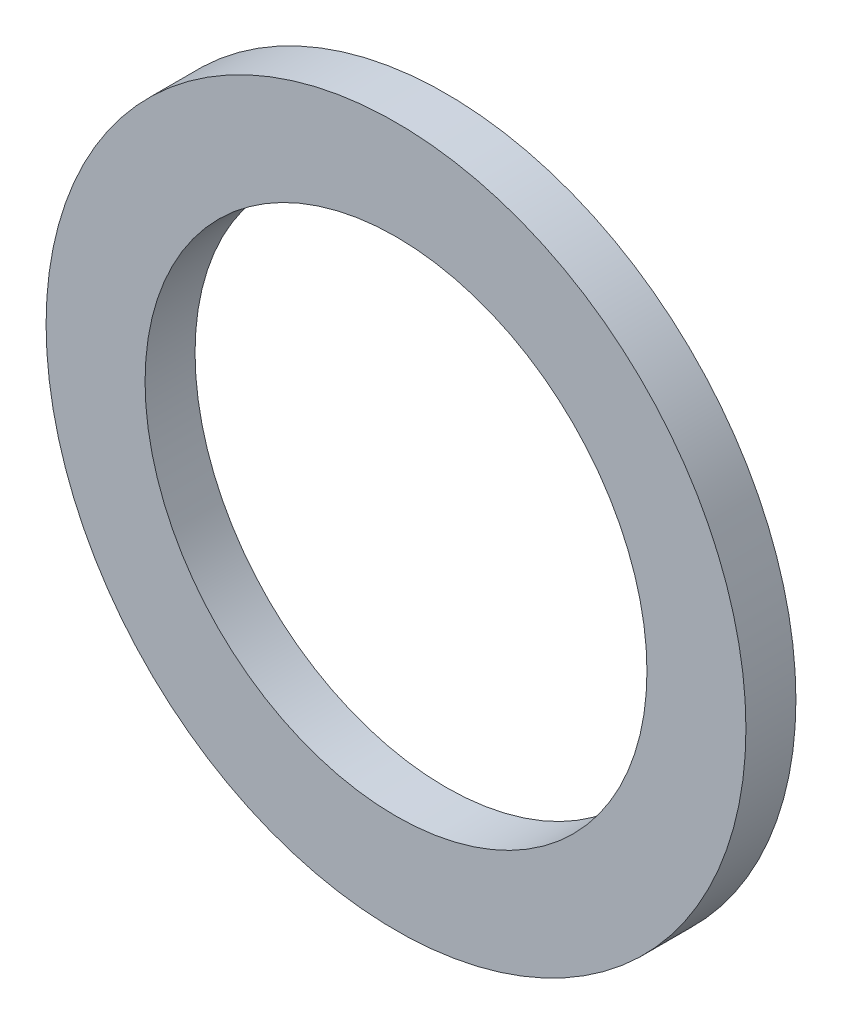
from build123d import *

# Parameters (mm, degrees)
SKETCH1_R           = 22.225
SKETCH1_R_2         = 15.9385
BOSS_EXTRUDE1_DEPTH = 3.175


with BuildPart() as part:
    # Sketch1 → Boss-Extrude1 (new body)
    with BuildSketch(Plane.XY):
        Circle(SKETCH1_R)
        Circle(SKETCH1_R_2, mode=Mode.SUBTRACT)
    extrude(amount=BOSS_EXTRUDE1_DEPTH)


solid = part.part
